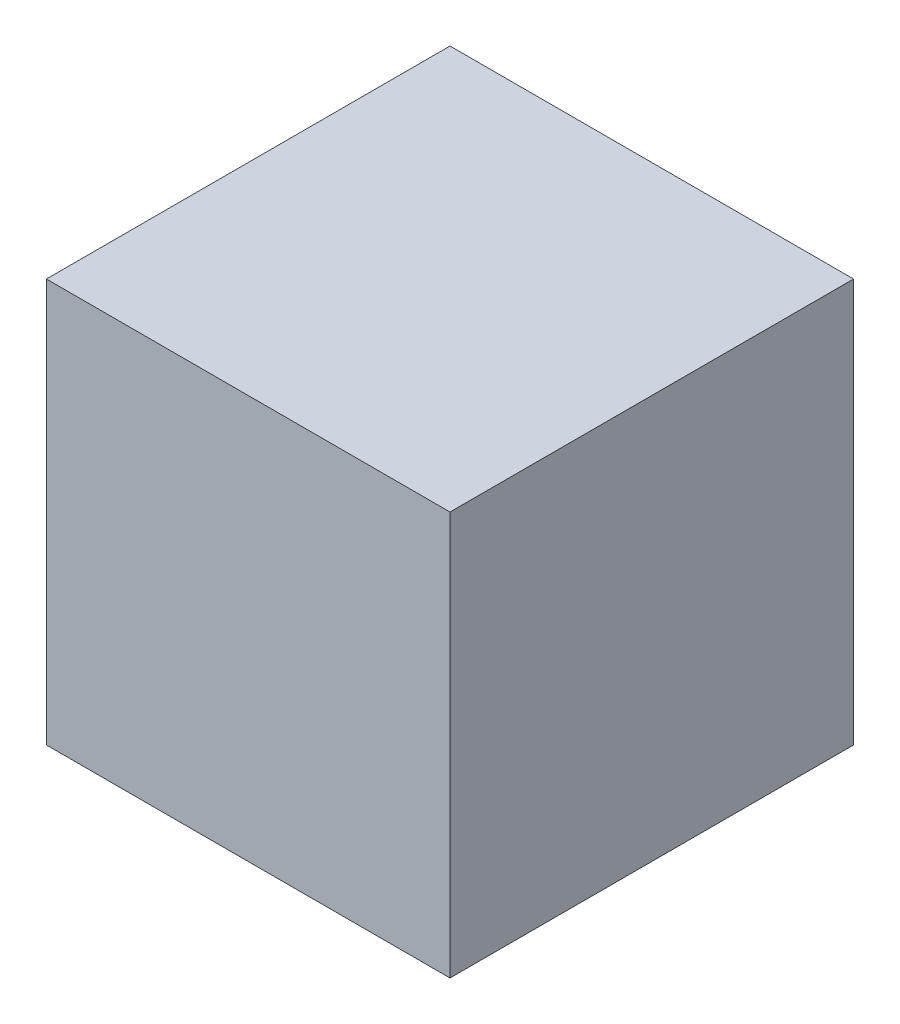
from build123d import *

# Parameters (mm, degrees)
SKETCH1_W           = 57
SKETCH1_H           = 57
BOSS_EXTRUDE1_DEPTH = 57


with BuildPart() as part:
    # Sketch1 → Boss-Extrude1 (new body)
    with BuildSketch(Plane.XY):
        Rectangle(SKETCH1_W, SKETCH1_H)
    extrude(amount=BOSS_EXTRUDE1_DEPTH)


solid = part.part
